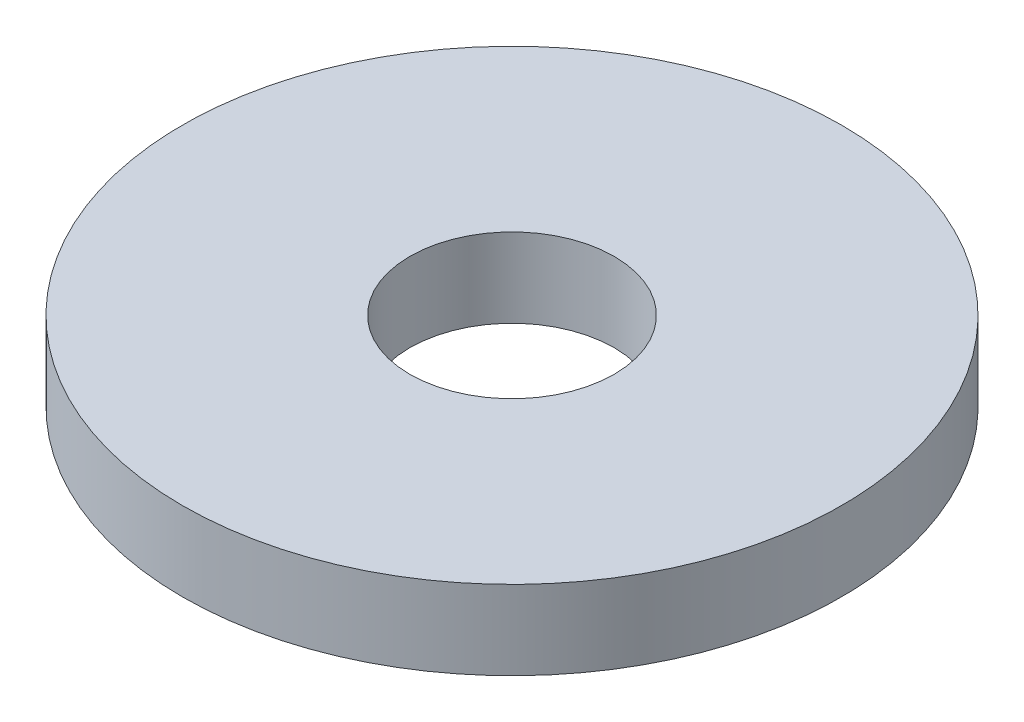
from build123d import *

# Parameters (mm, degrees)
SKETCH1_R           = 5
SKETCH1_R_2         = 1.55
BOSS_EXTRUDE1_DEPTH = 1.2


with BuildPart() as part:
    # Sketch1 → Boss-Extrude1 (new body)
    with BuildSketch(Plane(origin=(0, 0, 0), x_dir=(1, 0, 0), z_dir=(0, 1, 0))):
        Circle(SKETCH1_R)
        Circle(SKETCH1_R_2, mode=Mode.SUBTRACT)
    extrude(amount=BOSS_EXTRUDE1_DEPTH)


solid = part.part
